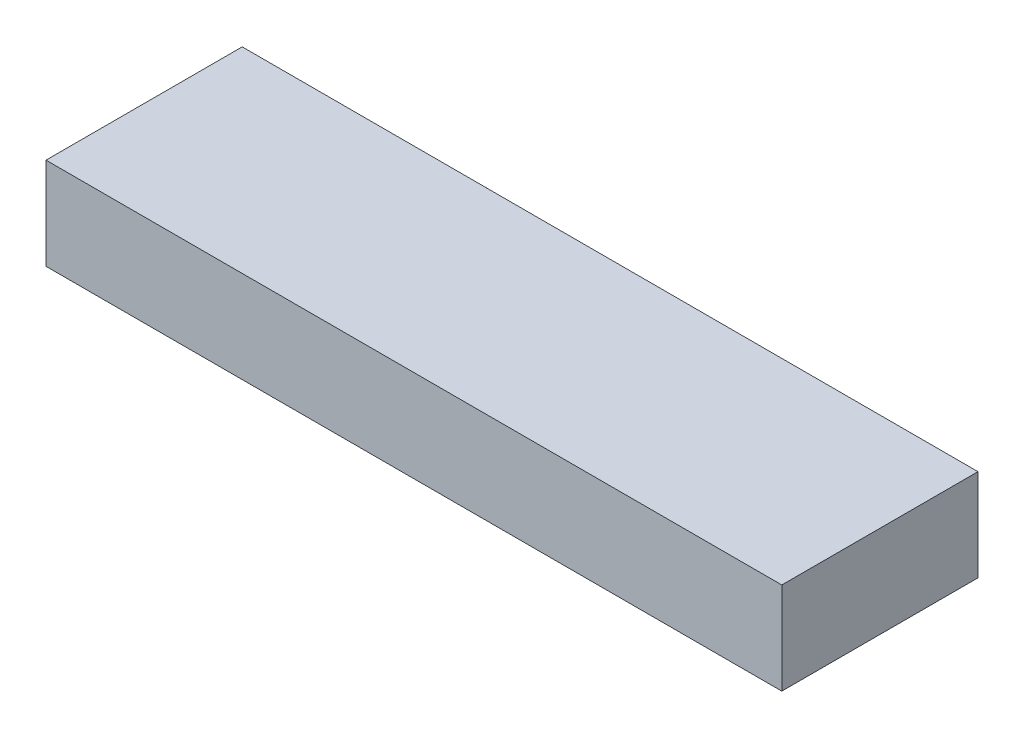
from build123d import *

# Parameters (mm, degrees)
SKETCH1_W           = 38.1
SKETCH1_H           = 10.16
BOSS_EXTRUDE1_DEPTH = 4.7625


with BuildPart() as part:
    # Sketch1 → Boss-Extrude1 (new body)
    with BuildSketch(Plane(origin=(0, 0, 0), x_dir=(1, 0, 0), z_dir=(0, 1, 0))):
        with Locations((19.05, 5.08)):
            Rectangle(SKETCH1_W, SKETCH1_H)
    extrude(amount=BOSS_EXTRUDE1_DEPTH)


solid = part.part
